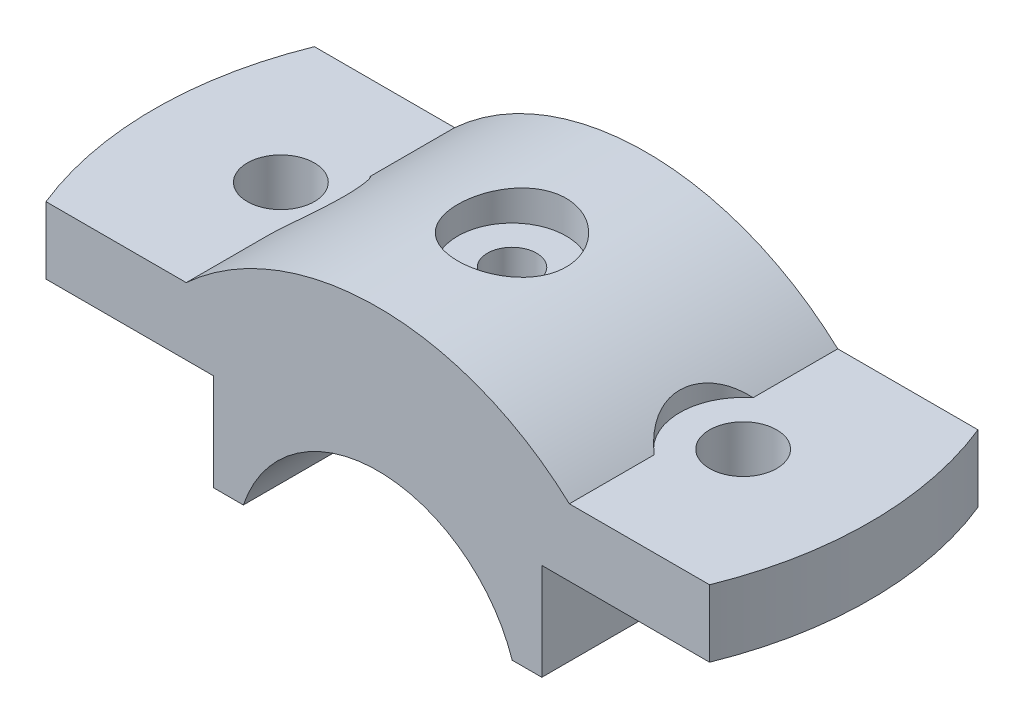
from build123d import *

# Parameters (mm, degrees)
BOSS_EXTRUDE1_DEPTH                     = 18
CUT_EXTRUDE1_DEPTH                      = 9
SKETCH5_R                               = 4.5
CUT_EXTRUDE2_DEPTH                      = 10
CUT_EXTRUDE3_DEPTH                      = 10
CBORE_FOR_M6_HEX_HEAD_BOLT4_D           = 6.6
CBORE_FOR_M6_HEX_HEAD_BOLT4_CBORE_D     = 14.55
CBORE_FOR_M6_HEX_HEAD_BOLT4_CBORE_DEPTH = 4.38


with BuildPart() as part:
    # Sketch1 → Boss-Extrude1 (new body, symmetric)
    with BuildSketch(Plane.XY):
        with BuildLine():
            Line((18.027756377, 6), (22, 6))
            Line((22, 6), (22, 19))
            Line((22, 19), (50, 19))
            Line((50, 19), (50, 28))
            Line((50, 28), (29.380930315, 28))
            Line((29.380930315, 28), (25.690465157, 28))
            ThreePointArc((25.690465157, 28), (0, 38), (-25.690465157, 28))
            Line((-25.690465157, 28), (-29.380930315, 28))
            Line((-29.380930315, 28), (-50, 28))
            Line((-50, 28), (-50, 19))
            Line((-50, 19), (-22, 19))
            Line((-22, 19), (-22, 6))
            Line((-22, 6), (-18.027756377, 6))
            ThreePointArc((-18.027756377, 6), (0, 19), (18.027756377, 6))
        make_face()
    extrude(amount=BOSS_EXTRUDE1_DEPTH, both=True)

    # Sketch4 → Cut-Extrude1 (cut)
    with BuildSketch(Plane(origin=(0, 28, 0), x_dir=(1, 0, 0), z_dir=(0, 1, 0))):
        with BuildLine():
            Line((-44.497190923, 18), (-50, 18))
            Line((-50, 18), (-50, -18))
            Line((-50, -18), (-44.497190923, -18))
            ThreePointArc((-44.497190923, -18), (-48, 0), (-44.497190923, 18))
        make_face()
    cut_extrude1 = extrude(amount=-CUT_EXTRUDE1_DEPTH, mode=Mode.SUBTRACT)

    # Mirror1: Cut-Extrude1 across plane
    add(cut_extrude1.mirror(Plane(origin=(0, 0, 0), x_dir=(0, 0, 1), z_dir=(1, 0, 0))), mode=Mode.SUBTRACT)

    # Sketch5 → Cut-Extrude2 (cut)
    with BuildSketch(Plane(origin=(0, 28, 0), x_dir=(1, 0, 0), z_dir=(0, 1, 0))):
        with Locations(Location((-31, 0, 0), (0, 0, 180))):  # turned: the seam where the file's is
            Circle(SKETCH5_R)
    cut_extrude2 = extrude(amount=-CUT_EXTRUDE2_DEPTH, mode=Mode.SUBTRACT)

    # Sketch7 → Cut-Extrude3 (cut)
    with BuildSketch(Plane(origin=(0, 28, 0), x_dir=(1, 0, 0), z_dir=(0, 1, 0))):
        with BuildLine():
            Line((-25.690465157, -6.637683312), (-25.690465157, 6.637683312))
            ThreePointArc((-25.690465157, 6.637683312), (-22.5, 0), (-25.690465157, -6.637683312))
        make_face()
    cut_extrude3 = extrude(amount=CUT_EXTRUDE3_DEPTH, mode=Mode.SUBTRACT)

    # Mirror2: Cut-Extrude2, Cut-Extrude3 across plane
    add(cut_extrude2.mirror(Plane(origin=(0, 0, 0), x_dir=(0, 0, 1), z_dir=(1, 0, 0))), mode=Mode.SUBTRACT)
    add(cut_extrude3.mirror(Plane(origin=(0, 0, 0), x_dir=(0, 0, 1), z_dir=(1, 0, 0))), mode=Mode.SUBTRACT)

    # CBORE for M6 Hex Head Bolt4 (through all)
    with Locations(Plane(origin=(0, 38, 0), x_dir=(1, 0, 0), z_dir=(0, 1, 0))):
        with Locations((0, 0)):
            CounterBoreHole(CBORE_FOR_M6_HEX_HEAD_BOLT4_D / 2, CBORE_FOR_M6_HEX_HEAD_BOLT4_CBORE_D / 2, CBORE_FOR_M6_HEX_HEAD_BOLT4_CBORE_DEPTH)


solid = part.part
